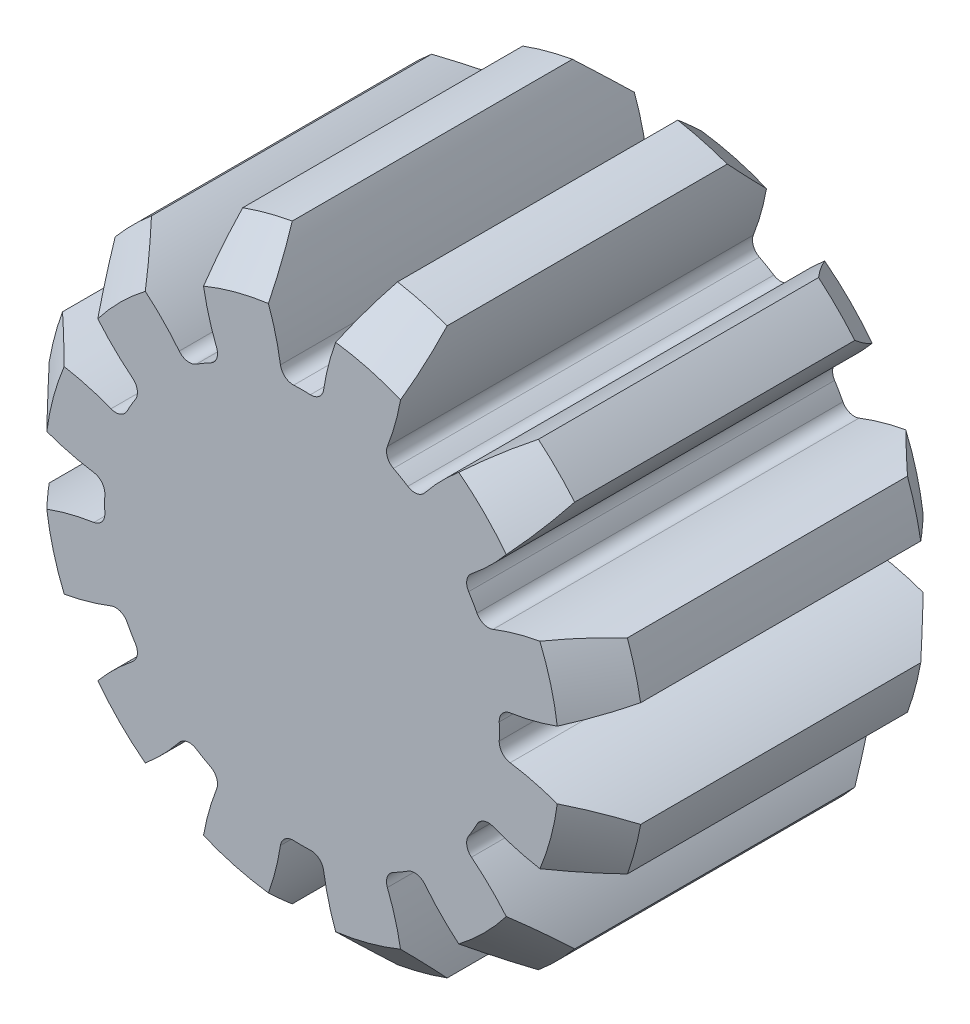
from build123d import *

# Parameters (mm, degrees)
SKETCH1_R                = 4.34999999
BOSS_EXTRUDE1_DEPTH      = 2.65
CUT_EXTRUDE1_DEPTH       = 3.65
FILLET1_R                = 0.186428571
CHAMFER1_SIZE            = 0.62142857
CIRPATTERN1_COUNT        = 12
FILLET1_OF_CIRPATTERN1_R = 0.186428571


with BuildPart() as part:
    # Sketch1 → Boss-Extrude1 (new body, symmetric)
    with BuildSketch(Plane.XY):
        Circle(SKETCH1_R)
    extrude(amount=BOSS_EXTRUDE1_DEPTH, both=True)

    # Sketch2 → Cut-Extrude1 (cut, symmetric)
    with BuildSketch(Plane.XY):
        with BuildLine():
            ThreePointArc((0.290990693, 2.843722031), (0, 2.858571422), (-0.290990693, 2.843722031))
            ThreePointArc((-0.290990693, 2.843722031), (-0.449301686, 3.588603553), (-0.762807674, 4.282595517))
            ThreePointArc((-0.762807674, 4.282595517), (0, 4.34999999), (0.762807674, 4.282595517))
            ThreePointArc((0.762807674, 4.282595517), (0.449301686, 3.588603553), (0.290990693, 2.843722031))
        make_face()
    cut_extrude1 = extrude(amount=CUT_EXTRUDE1_DEPTH, both=True, mode=Mode.SUBTRACT)

    # Fillet1
    fillet1_edges = [part.edges().sort_by_distance(p)[0] for p in [
        (0.290990693, 2.843722031, 0),
        (-0.290990693, 2.843722031, 0),
    ]]
    fillet(fillet1_edges, radius=FILLET1_R)

    # Chamfer1
    chamfer1_edges = [part.edges().sort_by_distance(p)[0] for p in [
        (0, -4.34999999, -2.65),
        (0, -4.34999999, 2.65),
    ]]
    chamfer(chamfer1_edges, length=CHAMFER1_SIZE)

    # CirPattern1: Cut-Extrude1 ×12 about axis
    cirpattern1_axis = Axis((0, 0, 0), (0, 0, 1))
    for i in range(1, CIRPATTERN1_COUNT):
        add(cut_extrude1.rotate(cirpattern1_axis, i * 360 / CIRPATTERN1_COUNT), mode=Mode.SUBTRACT)

    # Fillet1 of CirPattern1
    fillet1_of_cirpattern1_edges = [part.edges().sort_by_distance(p)[0] for p in [
        (-1.169855683, 2.608230867, 0),
        (-1.673866348, 2.317240174, 0),
        (-2.317240174, 1.673866348, 0),
        (-2.608230867, 1.169855683, 0),
        (-2.843722031, 0.290990693, 0),
        (-2.843722031, -0.290990693, 0),
        (-2.608230867, -1.169855683, 0),
        (-2.317240174, -1.673866348, 0),
        (-1.673866348, -2.317240174, 0),
        (-1.169855683, -2.608230867, 0),
        (-0.290990693, -2.843722031, 0),
        (0.290990693, -2.843722031, 0),
        (1.169855683, -2.608230867, 0),
        (1.673866348, -2.317240174, 0),
        (2.317240174, -1.673866348, 0),
        (2.608230867, -1.169855683, 0),
        (2.843722031, -0.290990693, 0),
        (2.843722031, 0.290990693, 0),
        (2.608230867, 1.169855683, 0),
        (2.317240174, 1.673866348, 0),
        (1.673866348, 2.317240174, 0),
        (1.169855683, 2.608230867, 0),
    ]]
    fillet(fillet1_of_cirpattern1_edges, radius=FILLET1_OF_CIRPATTERN1_R)


solid = part.part
